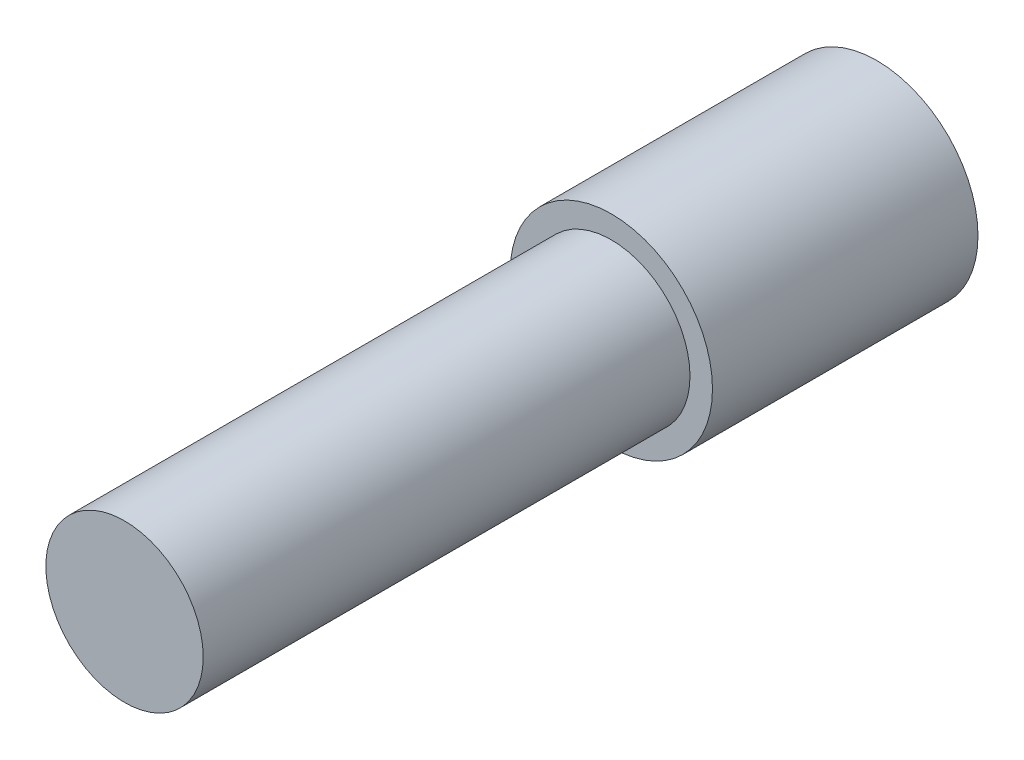
from build123d import *

# Parameters (mm, degrees)
SKETCH2_R           = 2.286
BOSS_EXTRUDE1_DEPTH = 6
SKETCH3_R           = 1.778
BOSS_EXTRUDE2_DEPTH = 11


with BuildPart() as part:
    # Sketch2 → Boss-Extrude1 (new body)
    with BuildSketch(Plane.XY):
        Circle(SKETCH2_R)
    extrude(amount=BOSS_EXTRUDE1_DEPTH)

    # Sketch3 → Boss-Extrude2 (add)
    with BuildSketch(Plane.XY.offset(6)):
        Circle(SKETCH3_R)
    extrude(amount=BOSS_EXTRUDE2_DEPTH)


solid = part.part
